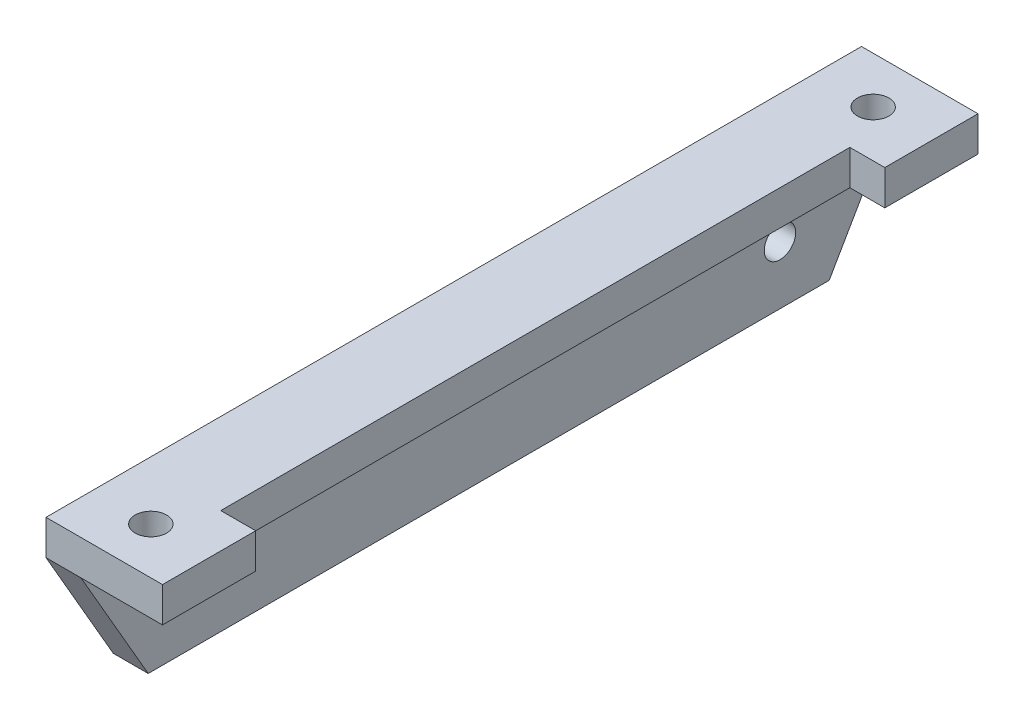
from build123d import *

# Parameters (mm, degrees)
SKETCH1_W               = 10
SKETCH1_H               = 70
BOSS_EXTRUDE1_DEPTH     = 3
SKETCH2_W               = 3
SKETCH2_H               = 70
BOSS_EXTRUDE2_DEPTH     = 10
SKETCH3_R               = 1.35
CUT_EXTRUDE1_DEPTH      = 1
CUT_EXTRUDE1_DEPTH_BACK = 14
SKETCH4_R               = 1.35
CUT_EXTRUDE2_DEPTH      = 10
CHAMFER1_SIZE           = 10
CHAMFER1_SIZE2          = 5.773502692
CHAMFER1_PART_2_SIZE    = 10
CHAMFER1_PART_2_SIZE2   = 5.773502692
SKETCH5_W               = 3
SKETCH5_H               = 54
CUT_EXTRUDE3_DEPTH      = 10


with BuildPart() as part:
    # Sketch1 → Boss-Extrude1 (new body)
    with BuildSketch(Plane(origin=(0, 0, 0), x_dir=(1, 0, 0), z_dir=(0, 1, 0))):
        with Locations((5, 0)):
            Rectangle(SKETCH1_W, SKETCH1_H)
    extrude(amount=BOSS_EXTRUDE1_DEPTH)

    # Sketch2 → Boss-Extrude2 (add)
    with BuildSketch(Plane.XZ):
        with Locations((1.5, 0)):
            Rectangle(SKETCH2_W, SKETCH2_H)
    extrude(amount=BOSS_EXTRUDE2_DEPTH)

    # Sketch3 → Cut-Extrude1 (cut, two sides)
    with BuildSketch(Plane(origin=(0, 3, 0), x_dir=(1, 0, 0), z_dir=(0, 1, 0))) as cut_extrude1_sk:
        with Locations((5, 31)):
            Circle(SKETCH3_R)
        with Locations((5, -31)):
            Circle(SKETCH3_R)
    extrude(amount=CUT_EXTRUDE1_DEPTH, mode=Mode.SUBTRACT)
    extrude(cut_extrude1_sk.sketch, amount=-CUT_EXTRUDE1_DEPTH_BACK, mode=Mode.SUBTRACT)

    # Sketch4 → Cut-Extrude2 (cut)
    with BuildSketch(Plane(origin=(3, 0, 0), x_dir=(0, 0, -1), z_dir=(1, 0, 0))):
        with Locations((25, -5)):
            Circle(SKETCH4_R)
        with Locations((-25, -5)):
            Circle(SKETCH4_R)
    extrude(amount=-CUT_EXTRUDE2_DEPTH, mode=Mode.SUBTRACT)

    # Chamfer1
    chamfer1_edges = [part.edges().sort_by_distance(p)[0] for p in [
        (1.5, -10, -35),
    ]]
    chamfer1_side = [part.faces().sort_by_distance(p)[0] for p in [
        (9.835987805, 1.5, -35),
    ]]
    chamfer(chamfer1_edges, length=CHAMFER1_SIZE, length2=CHAMFER1_SIZE2, reference=chamfer1_side[0])

    # Chamfer1 part 2
    chamfer1_part_2_edges = [part.edges().sort_by_distance(p)[0] for p in [
        (1.5, -10, 35),
    ]]
    chamfer1_part_2_side = [part.faces().sort_by_distance(p)[0] for p in [
        (0.164012195, -3.5, 35),
    ]]
    chamfer(chamfer1_part_2_edges, length=CHAMFER1_PART_2_SIZE, length2=CHAMFER1_PART_2_SIZE2, reference=chamfer1_part_2_side[0])

    # Sketch5 → Cut-Extrude3 (cut)
    with BuildSketch(Plane(origin=(0, 3, 0), x_dir=(1, 0, 0), z_dir=(0, 1, 0))):
        with Locations((8.5, 0)):
            Rectangle(SKETCH5_W, SKETCH5_H)
    extrude(amount=-CUT_EXTRUDE3_DEPTH, mode=Mode.SUBTRACT)


solid = part.part
